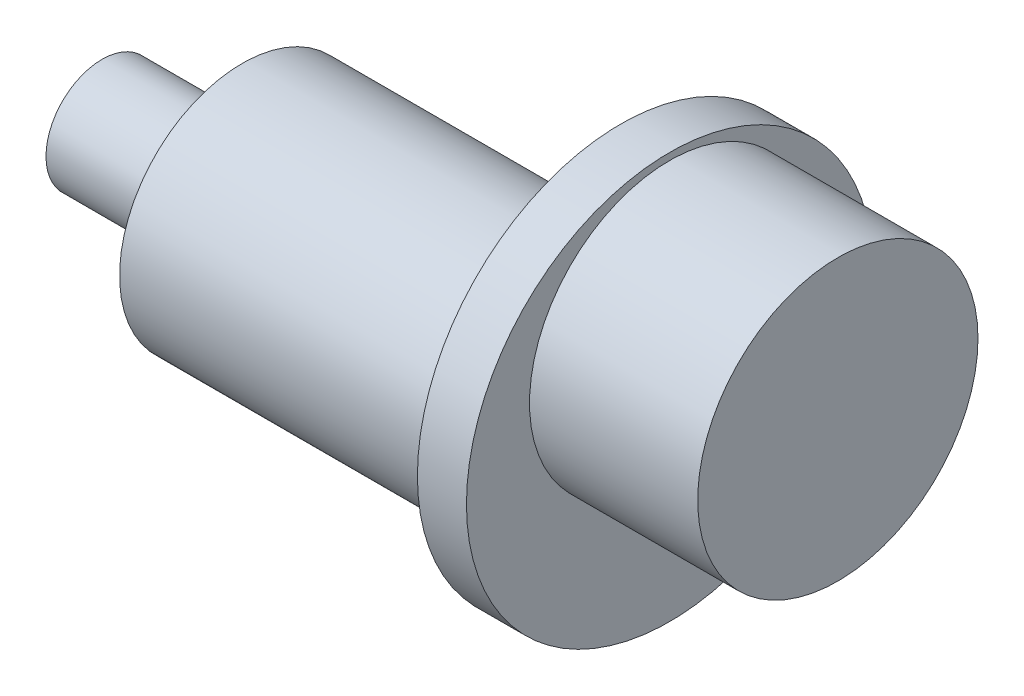
from build123d import *

# Parameters (mm, degrees)
ESQUISSE2_R        = 17.5
BOSS_EXTRU_1_DEPTH = 47
ESQUISSE3_R        = 8
BOSS_EXTRU_2_DEPTH = 20
ESQUISSE4_R        = 20.5
BOSS_EXTRU_3_DEPTH = 7
ESQUISSE5_R        = 29
BOSS_EXTRU_4_DEPTH = 7
ESQUISSE6_R        = 20
BOSS_EXTRU_5_DEPTH = 24


with BuildPart() as part:
    # Esquisse2 → Boss.-Extru.1 (new body)
    with BuildSketch(Plane(origin=(0, 0, 0), x_dir=(0, 0, -1), z_dir=(1, 0, 0))):
        Circle(ESQUISSE2_R)
    extrude(amount=-BOSS_EXTRU_1_DEPTH)

    # Esquisse3 → Boss.-Extru.2 (add)
    with BuildSketch(Plane.ZY.offset(47)):
        Circle(ESQUISSE3_R)
    extrude(amount=BOSS_EXTRU_2_DEPTH)

    # Esquisse4 → Boss.-Extru.3 (add)
    with BuildSketch(Plane(origin=(0, 0, 0), x_dir=(0, 0, -1), z_dir=(1, 0, 0))):
        Circle(ESQUISSE4_R)
    extrude(amount=BOSS_EXTRU_3_DEPTH)

    # Esquisse5 → Boss.-Extru.4 (add)
    with BuildSketch(Plane(origin=(7, 0, 0), x_dir=(0, 0, -1), z_dir=(1, 0, 0))):
        with Locations((0, 8)):
            Circle(ESQUISSE5_R)
    extrude(amount=BOSS_EXTRU_4_DEPTH)

    # Esquisse6 → Boss.-Extru.5 (add)
    with BuildSketch(Plane(origin=(14, 0, 0), x_dir=(0, 0, -1), z_dir=(1, 0, 0))):
        with Locations((0, 16)):
            Circle(ESQUISSE6_R)
    extrude(amount=BOSS_EXTRU_5_DEPTH)


solid = part.part
